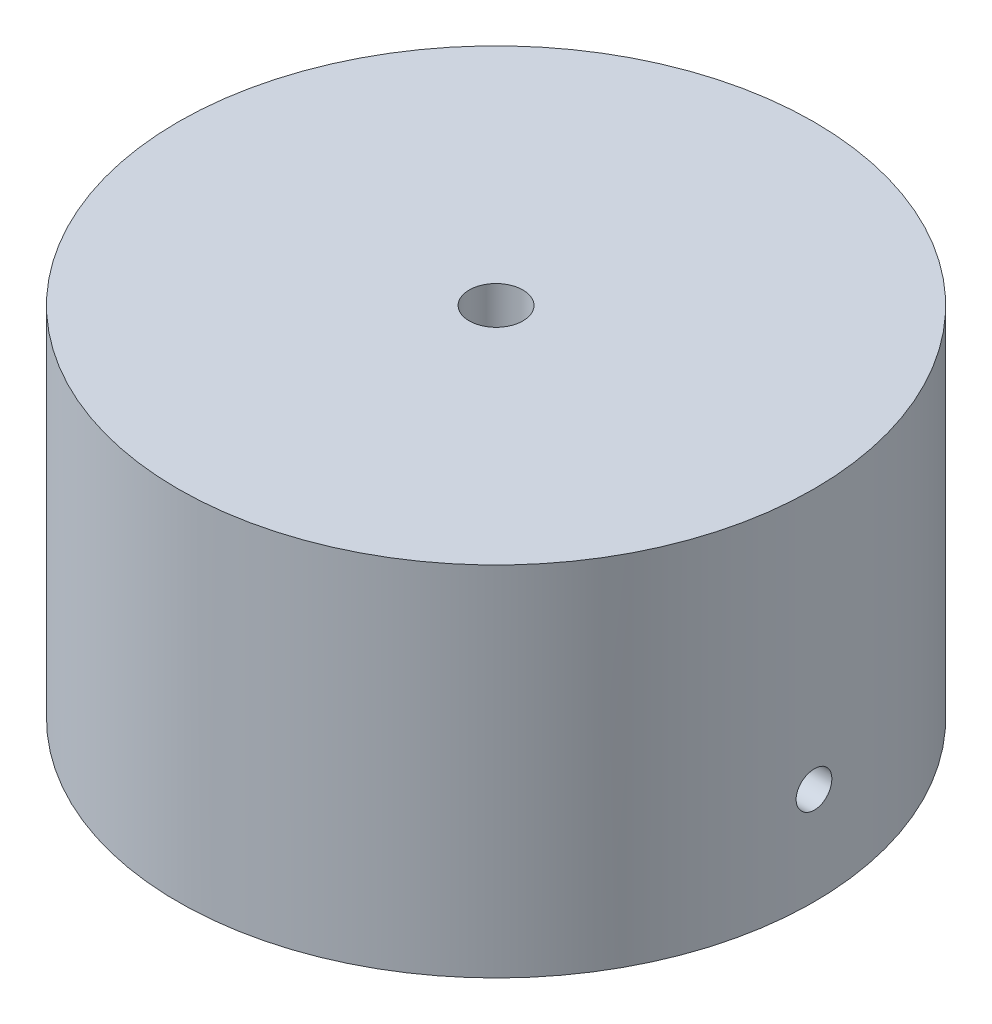
from build123d import *

# Parameters (mm, degrees)
ESQUISSE1_R           = 40
BOSS_EXTRU_1_DEPTH    = 15
ESQUISSE5_R           = 40
ESQUISSE5_R_2         = 35.1
BOSS_EXTRU_2_DEPTH    = 30
D_GAGEMENT_M41_REACH  = 97.28
D_GAGEMENT_M41_BORE_R = 2.25


with BuildPart() as part:
    # Esquisse1 → Boss.-Extru.1 (new body)
    with BuildSketch(Plane(origin=(0, 0, 0), x_dir=(1, 0, 0), z_dir=(0, 1, 0))):
        with Locations(Location((0, 0, 0), (0, 0, 270))):
            Circle(ESQUISSE1_R)
    extrude(amount=BOSS_EXTRU_1_DEPTH)

    # Esquisse5 → Boss.-Extru.2 (add)
    with BuildSketch(Plane.XZ):
        with Locations(Location((0, 0, 0), (0, 0, 270))):
            Circle(ESQUISSE5_R)
        with Locations(Location((0, 0, 0), (0, 0, 270))):
            Circle(ESQUISSE5_R_2, mode=Mode.SUBTRACT)
    extrude(amount=BOSS_EXTRU_2_DEPTH)

    # Dégagement M41 bore (on position points) → Dégagement M41 (cut, up to next)
    with BuildSketch(Plane(origin=(39.999952301, -17.76077449, -0.061772988), x_dir=(0.0015443247, 0, 0.99999880753), z_dir=(0.99999880753, 0, -0.0015443247)), mode=Mode.PRIVATE) as d_gagement_m41_sk1:
        Circle(D_GAGEMENT_M41_BORE_R)
    d_gagement_m41_tool1 = extrude(d_gagement_m41_sk1.sketch, amount=-D_GAGEMENT_M41_REACH, mode=Mode.PRIVATE) & part.part
    add(d_gagement_m41_tool1.solids().sort_by_distance((39.999952, -17.760774, -0.061773))[0], mode=Mode.SUBTRACT)

    # Esquisse11 → Dégagement 1/41 (revolve, cut)
    with BuildSketch(Plane(origin=(0, 15, 0), x_dir=(0, 0, 1), z_dir=(1, 0, 0))):
        Polygon((0, 0), (0, 12.029827343), (3.3782, 10), (3.3782, 0), align=None)
    revolve(axis=Axis((0, 21.35, 0), (0, -1, 0)), mode=Mode.SUBTRACT)


solid = part.part
